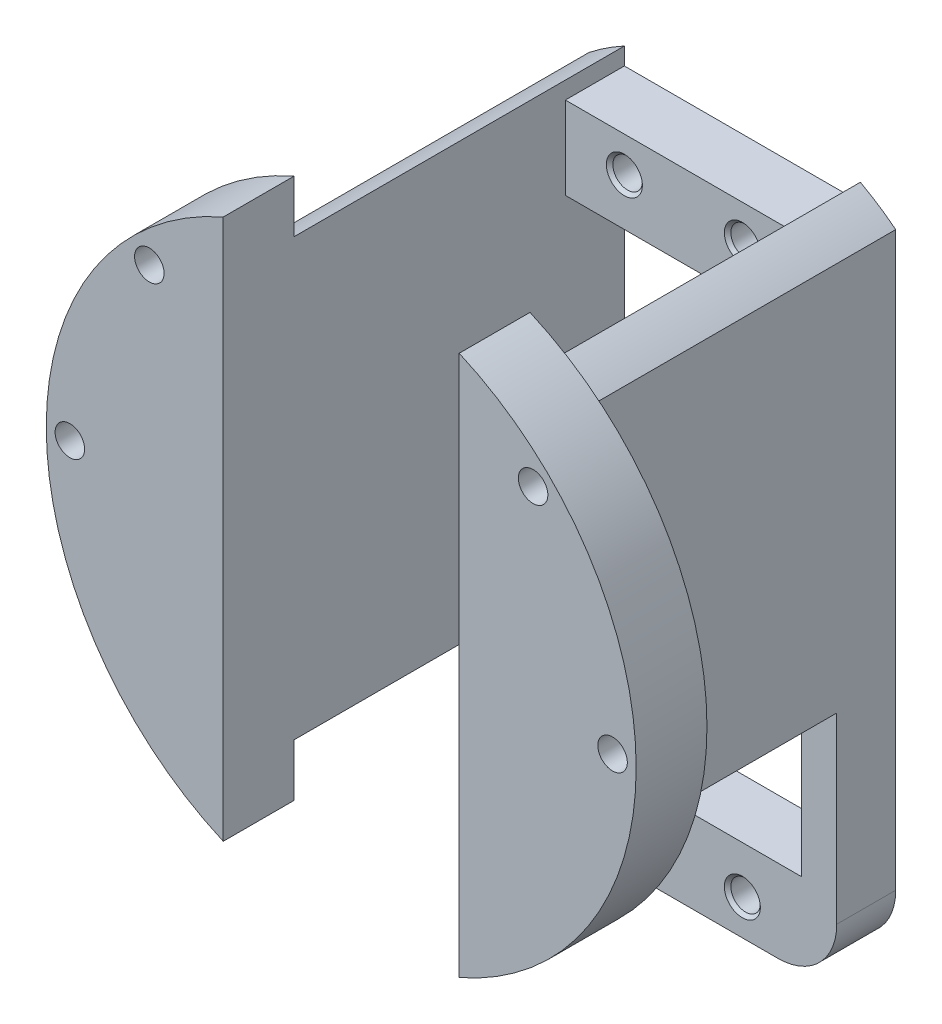
from build123d import *

# Parameters (mm, degrees)
SKETCH_1_W                  = 26
SKETCH_1_H                  = 54
SKETCH_1_W_2                = 20
SKETCH_1_H_2                = 40
EXTRUDE_1_DEPTH             = 5
EXTRUDE_2_DEPTH             = 28
SKETCH_3_OUTSIDE_W          = 41.47
SKETCH_3_OUTSIDE_H          = 70.936
CUT_EXTRUDE_1_DEPTH         = 29
FILLET_1_R                  = 5
EXTRUDE_3_DEPTH             = 6
M3X0_51_D                   = 2.5
M3X0_51_CSINK_D             = 3.05
M3X0_51_CSINK_ANGLE         = 90
PATTERN_LINEAR_1_COUNT      = 2
PATTERN_LINEAR_1_PITCH      = 10
PATTERN_LINEAR_1_COUNT_DIR2 = 2
PATTERN_LINEAR_1_PITCH_DIR2 = 48
HOLE_WIZARD_1_D             = 2.5
PATTERN_CIRCULAR_1_COUNT    = 8


with BuildPart() as part:
    # Эскиз1 → Бобышка-Вытянуть1 (new body)
    with BuildSketch(Plane.XY):
        with Locations((0, -10)):
            Rectangle(SKETCH_1_W, SKETCH_1_H)
        with Locations((0, -10)):
            Rectangle(SKETCH_1_W_2, SKETCH_1_H_2, mode=Mode.SUBTRACT)
    extrude(amount=EXTRUDE_1_DEPTH)

    # Эскиз2 → Бобышка-Вытянуть2 (add)
    with BuildSketch(Plane.XY):
        with BuildLine():
            Line((10, -18.466185313), (10, 18.466185313))
            ThreePointArc((10, 18.466185313), (11.542267321, 17.543547677), (13, 16.492422502))
            Line((13, 16.492422502), (13, -16.492422502))
            ThreePointArc((13, -16.492422502), (11.542267321, -17.543547677), (10, -18.466185313))
        make_face()
        with BuildLine():
            Line((-10, -18.466185313), (-10, 18.466185313))
            ThreePointArc((-10, 18.466185313), (-11.542267321, 17.543547677), (-13, 16.492422502))
            Line((-13, 16.492422502), (-13, -16.492422502))
            ThreePointArc((-13, -16.492422502), (-11.542267321, -17.543547677), (-10, -18.466185313))
        make_face()
    extrude(amount=EXTRUDE_2_DEPTH)

    # Эскиз3 outside → Вырез-Вытянуть1 (cut, through all)
    with BuildSketch(Plane.XY.offset(28)):
        with Locations((0, -9.267)):
            Rectangle(SKETCH_3_OUTSIDE_W, SKETCH_3_OUTSIDE_H)
        with BuildLine():
            Line((-13, -16.492422502), (-13, -37))
            Line((-13, -37), (13, -37))
            Line((13, -37), (13, -16.492422502))
            ThreePointArc((13, -16.492422502), (0, 21), (-13, -16.492422502))
        make_face(mode=Mode.SUBTRACT)
    extrude(amount=-CUT_EXTRUDE_1_DEPTH, mode=Mode.SUBTRACT)

    # Скругление1
    fillet_1_edges = [part.edges().sort_by_distance(p)[0] for p in [
        (13, -37, 2.5),
        (-13, -37, 2.5),
    ]]
    fillet(fillet_1_edges, radius=FILLET_1_R)

    # Эскиз7 → Бобышка-Вытянуть3 (add)
    with BuildSketch(Plane.XY.offset(28)):
        with BuildLine():
            Line((-10, -22.912878475), (-10, 22.912878475))
            ThreePointArc((-10, 22.912878475), (-25, 0), (-10, -22.912878475))
        make_face()
        with BuildLine():
            Line((10, -22.912878475), (10, 22.912878475))
            ThreePointArc((10, 22.912878475), (25, 0), (10, -22.912878475))
        make_face()
    extrude(amount=EXTRUDE_3_DEPTH)

    # Отверстие обработанное метчиком M3x0.51 (through all)
    with Locations(Plane.XY.offset(5)):
        with Locations((-5, 14)):
            m3x0_51 = CounterSinkHole(M3X0_51_D / 2, M3X0_51_CSINK_D / 2, counter_sink_angle=M3X0_51_CSINK_ANGLE)

    # Линейный массив1: M3x0.51 2 × 2
    with Locations(*[(i * PATTERN_LINEAR_1_PITCH, -j * PATTERN_LINEAR_1_PITCH_DIR2, 0) for i in range(PATTERN_LINEAR_1_COUNT) for j in range(PATTERN_LINEAR_1_COUNT_DIR2) if (i, j) != (0, 0)]):
        add(m3x0_51, mode=Mode.SUBTRACT)

    # Отверстие1 (through all)
    with Locations(Plane.XY.offset(34)):
        with Locations((-23, 0)):
            hole_wizard_1 = Hole(HOLE_WIZARD_1_D / 2)

    # Круговой массив1: Отверстие1 ×8 about axis, 4 skipped
    pattern_circular_1_axis = Axis((0, 0, 34), (0, 0, 1))
    add([hole_wizard_1.rotate(pattern_circular_1_axis, i * 360 / PATTERN_CIRCULAR_1_COUNT) for i in range(1, PATTERN_CIRCULAR_1_COUNT) if i not in (1, 2, 3, 6)], mode=Mode.SUBTRACT)


solid = part.part
